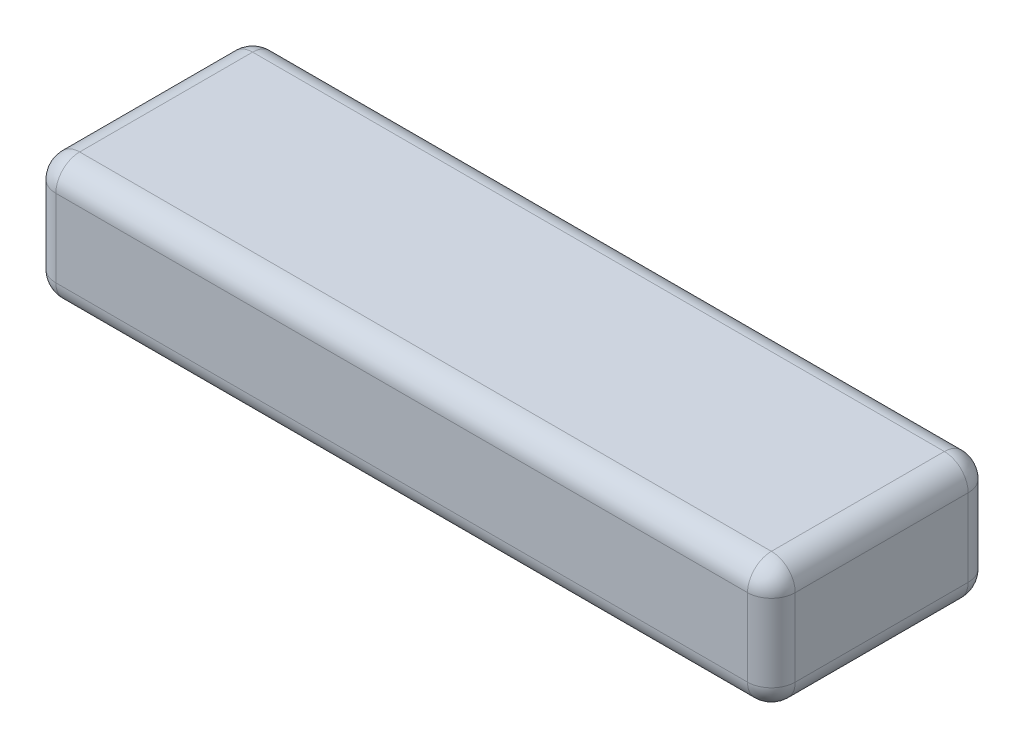
from build123d import *

# Parameters (mm, degrees)
SKETCH1_W           = 62
SKETCH1_H           = 18.5
BOSS_EXTRUDE1_DEPTH = 5.25
FILLET1_R           = 2


with BuildPart() as part:
    # Sketch1 → Boss-Extrude1 (new body, symmetric)
    with BuildSketch(Plane(origin=(0, 0, 0), x_dir=(1, 0, 0), z_dir=(0, 1, 0))):
        Rectangle(SKETCH1_W, SKETCH1_H)
    extrude(amount=BOSS_EXTRUDE1_DEPTH, both=True)

    # Fillet1
    fillet1_edges = [part.edges().sort_by_distance(p)[0] for p in [
        (-31, 5.25, 0),
        (0, 5.25, 9.25),
        (31, 5.25, 0),
        (0, -5.25, 9.25),
        (-31, -5.25, 0),
        (0, -5.25, -9.25),
        (31, -5.25, 0),
        (31, 0, 9.25),
        (-31, 0, 9.25),
        (-31, 0, -9.25),
        (31, 0, -9.25),
        (0, 5.25, -9.25),
    ]]
    fillet(fillet1_edges, radius=FILLET1_R)


solid = part.part
